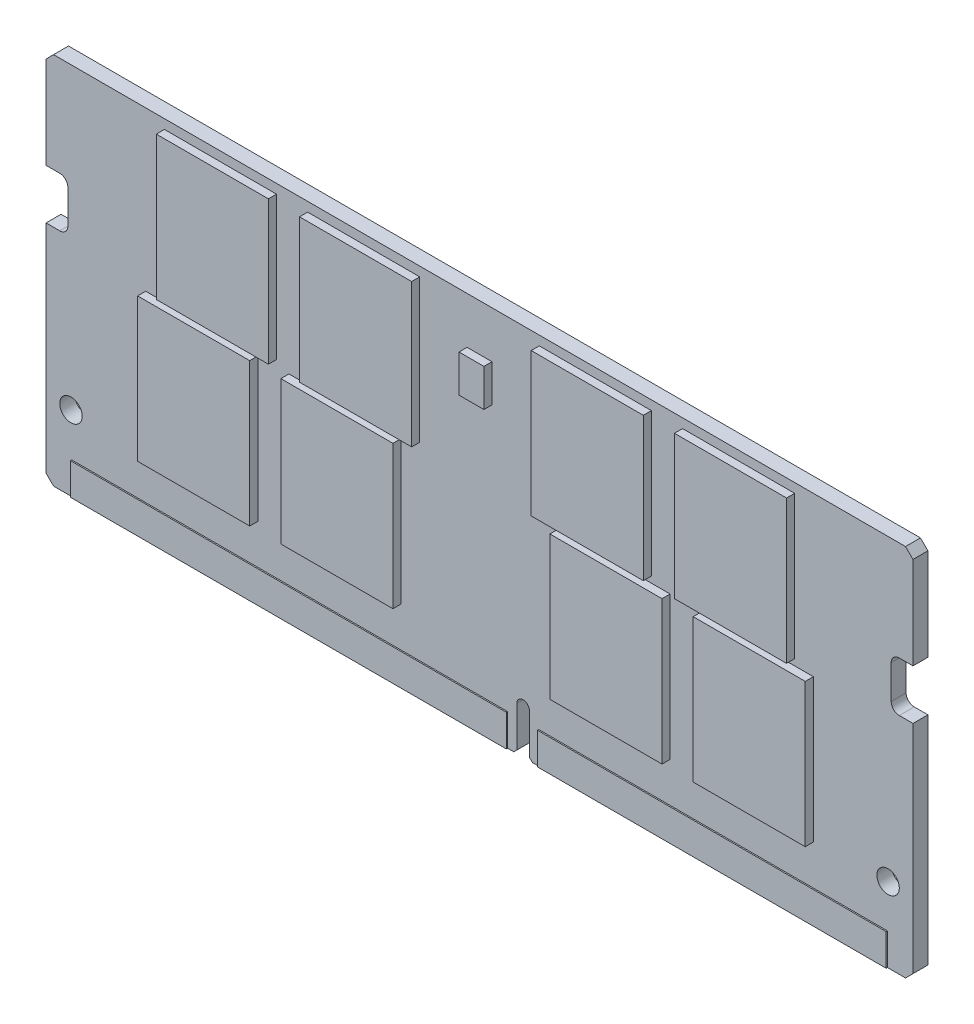
from build123d import *

# Parameters (mm, degrees)
MAIN_BOARD_DEPTH    = 1.2
SKETCH2_R           = 0.9
DETAIL_CUTS_DEPTH   = 1.2
CHAMFER1_SIZE       = 0.25
SKETCH3_W           = 9
SKETCH3_H           = 11.5
SOC1_DEPTH          = 0.65
SOC1_DEPTH_BACK     = 1.85
SKETCH4_W           = 2
SKETCH4_H           = 3
SOC2_DEPTH          = 0.65
SKETCH5_W           = 35
SKETCH5_H           = 2.55
SKETCH5_W_2         = 28
CONTACTS_DEPTH      = 0.1
CONTACTS_DEPTH_BACK = 1.3


with BuildPart() as part:
    # Sketch1 → Main Board (new body)
    with BuildSketch(Plane.XY):
        Polygon((-34.2, 15), (-34.8, 14.4), (-34.8, -14.4), (-34.2, -15), (34.2, -15), (34.8, -14.4), (34.8, 14.4), (34.2, 15), align=None)
    extrude(amount=MAIN_BOARD_DEPTH)

    # Sketch2 → Detail Cuts (cut)
    with BuildSketch(Plane.XY.offset(1.2)):
        with Locations((-32.8, -9)):
            Circle(SKETCH2_R)
        with Locations((32.8, -9)):
            Circle(SKETCH2_R)
        with BuildLine():
            Line((-36.55, 3), (-33.7, 3))
            ThreePointArc((-33.7, 3), (-33.240380592, 3.190380592), (-33.05, 3.65))
            Line((-33.05, 3.65), (-33.05, 6.35))
            ThreePointArc((-33.05, 6.35), (-33.240380592, 6.809619408), (-33.7, 7))
            Line((-33.7, 7), (-36.55, 7))
            Line((-36.55, 7), (-36.55, 3))
        make_face()
        with BuildLine():
            Line((33.05, 3.65), (33.05, 6.35))
            ThreePointArc((33.05, 6.35), (33.240380592, 6.809619408), (33.7, 7))
            Line((33.7, 7), (36.55, 7))
            Line((36.55, 7), (36.55, 3))
            Line((36.55, 3), (33.7, 3))
            ThreePointArc((33.7, 3), (33.240380592, 3.190380592), (33.05, 3.65))
        make_face()
        with BuildLine():
            Line((3, -15), (3, -11.5))
            ThreePointArc((3, -11.5), (3.5, -11), (4, -11.5))
            Line((4, -11.5), (4, -15))
            ThreePointArc((4, -15), (3.5, -15.5), (3, -15))
        make_face()
    extrude(amount=-DETAIL_CUTS_DEPTH, mode=Mode.SUBTRACT)

    # Chamfer1
    chamfer1_edges = [part.edges().sort_by_distance(p)[0] for p in [
        (4, -15, 0.6),
        (3, -15, 0.6),
    ]]
    chamfer(chamfer1_edges, length=CHAMFER1_SIZE)

    # Sketch3 → SOC1 (add, two sides)
    with BuildSketch(Plane(origin=(0, 0, 0), x_dir=(-1, 0, 0), z_dir=(0, 0, -1))) as soc1_sk:
        with Locations((-20.8, 8.5)):
            Rectangle(SKETCH3_W, SKETCH3_H)
        with Locations((-9.3, 8.5)):
            Rectangle(SKETCH3_W, SKETCH3_H)
        with Locations((10.8, -3.5)):
            Rectangle(SKETCH3_W, SKETCH3_H)
        with Locations((-22.3, -3.5)):
            Rectangle(SKETCH3_W, SKETCH3_H)
        with Locations((-10.8, -3.5)):
            Rectangle(SKETCH3_W, SKETCH3_H)
        with Locations((22.3, -3.5)):
            Rectangle(SKETCH3_W, SKETCH3_H)
        with Locations((9.3, 8.5)):
            Rectangle(SKETCH3_W, SKETCH3_H)
        with Locations((20.8, 8.5)):
            Rectangle(SKETCH3_W, SKETCH3_H)
    extrude(amount=SOC1_DEPTH)
    extrude(soc1_sk.sketch, amount=-SOC1_DEPTH_BACK)

    # Sketch4 → SOC2 (add)
    with BuildSketch(Plane.XY.offset(1.2)):
        with Locations((0, 9.75)):
            Rectangle(SKETCH4_W, SKETCH4_H)
    extrude(amount=SOC2_DEPTH)

    # Sketch5 → Contacts (add, two sides)
    with BuildSketch(Plane.XY.offset(1.2)) as contacts_sk:
        with Locations((-15.25, -13.725)):
            Rectangle(SKETCH5_W, SKETCH5_H)
        with Locations((18.75, -13.725)):
            Rectangle(SKETCH5_W_2, SKETCH5_H)
    extrude(amount=CONTACTS_DEPTH)
    extrude(contacts_sk.sketch, amount=-CONTACTS_DEPTH_BACK)


solid = part.part
